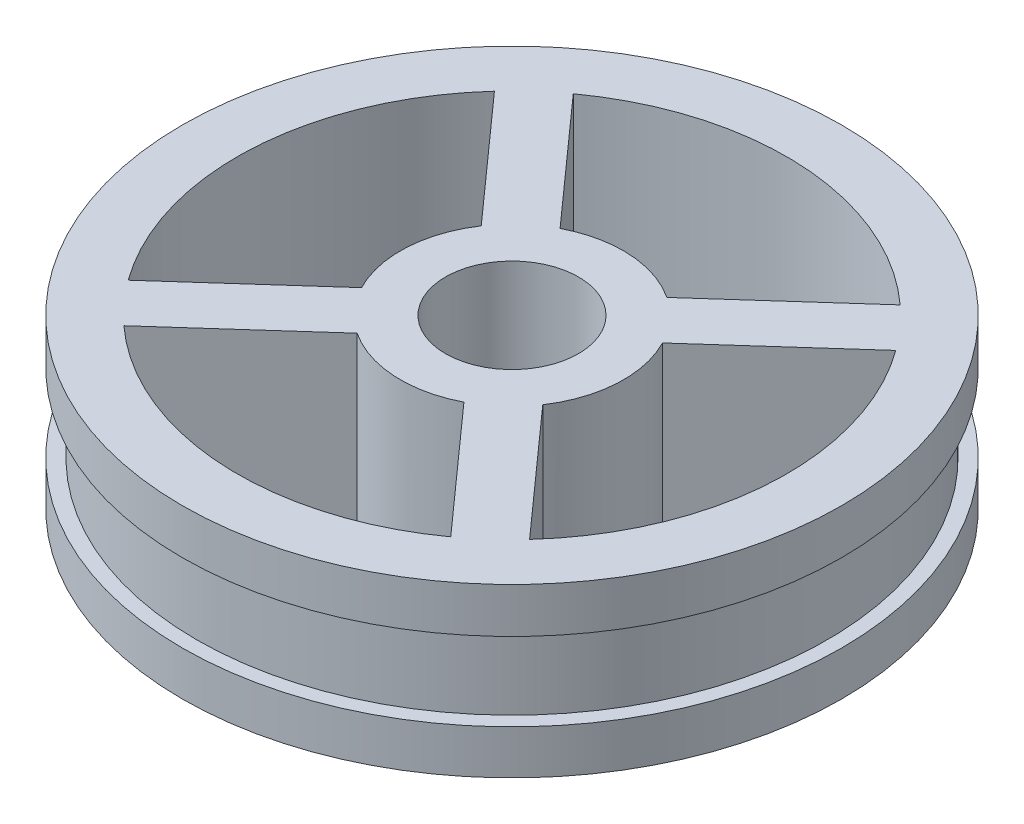
from build123d import *

# Parameters (mm, degrees)
SKETCH1_R                = 30
SKETCH1_R_2              = 25
BOSS_EXTRUDE1_DEPTH      = 15.24
BOSS_EXTRUDE2_DEPTH      = 15.24
SKETCH3_R                = 10.16
BOSS_EXTRUDE3_DEPTH      = 10
BOSS_EXTRUDE3_DEPTH_BACK = 15.24
SKETCH14_R               = 38.1
SKETCH14_R_2             = 28.702
CUT_EXTRUDE1_DEPTH       = 0.89229946
CUT_EXTRUDE1_DEPTH_BACK  = 6.22629946
CUT_EXTRUDE2_DEPTH       = 6.35
SKETCH19_R               = 2.032
CUT_EXTRUDE3_DEPTH       = 18.89
SKETCH20_R               = 6.052064437
CUT_EXTRUDE4_DEPTH       = 15.24


with BuildPart() as part:
    # Sketch1 → Boss-Extrude1 (new body)
    with BuildSketch(Plane(origin=(0, 0, 0), x_dir=(1, 0, 0), z_dir=(0, 1, 0))):
        Circle(SKETCH1_R)
        Circle(SKETCH1_R_2, mode=Mode.SUBTRACT)
    extrude(amount=BOSS_EXTRUDE1_DEPTH)

    # Sketch2 → Boss-Extrude2 (add)
    with BuildSketch(Plane(origin=(0, 15.24, 0), x_dir=(1, 0, 0), z_dir=(0, 1, 0))):
        Polygon((3.584352377, -0.200805771), (0.201044225, 3.588608735), (-3.584352377, 0.200805771), (-0.201044225, -3.588608735), align=None)
        with BuildLine():
            ThreePointArc((20.22640903, 14.693276617), (18.628907162, 16.672246937), (16.838608452, 18.478670552))
            Line((16.838608452, 18.478670552), (0.201044225, 3.588608735))
            Line((0.201044225, 3.588608735), (3.584352377, -0.200805771))
            Line((3.584352377, -0.200805771), (20.22640903, 14.693276617))
        make_face()
        with BuildLine():
            Line((-3.584352377, 0.200805771), (0.201044225, 3.588608735))
            Line((0.201044225, 3.588608735), (-14.669262011, 20.243832445))
            ThreePointArc((-14.669262011, 20.243832445), (-16.650126818, 18.648680301), (-18.458673848, 16.860526676))
            Line((-18.458673848, 16.860526676), (-3.584352377, 0.200805771))
        make_face()
        with BuildLine():
            Line((-0.201044225, -3.588608735), (-3.584352377, 0.200805771))
            Line((-3.584352377, 0.200805771), (-20.22640903, -14.693276617))
            ThreePointArc((-20.22640903, -14.693276617), (-18.628907162, -16.672246937), (-16.838608452, -18.478670552))
            Line((-16.838608452, -18.478670552), (-0.201044225, -3.588608735))
        make_face()
        with BuildLine():
            Line((18.458673848, -16.860526676), (3.584352377, -0.200805771))
            Line((3.584352377, -0.200805771), (-0.201044225, -3.588608735))
            Line((-0.201044225, -3.588608735), (14.669262011, -20.243832445))
            ThreePointArc((14.669262011, -20.243832445), (16.650126818, -18.648680301), (18.458673848, -16.860526676))
        make_face()
    extrude(amount=-BOSS_EXTRUDE2_DEPTH)

    # Sketch3 → Boss-Extrude3 (add, two sides)
    with BuildSketch(Plane(origin=(0, 0, 0), x_dir=(-1, 0, 0), z_dir=(0, -1, 0))) as boss_extrude3_sk:
        Circle(SKETCH3_R)
    extrude(amount=BOSS_EXTRUDE3_DEPTH)
    extrude(boss_extrude3_sk.sketch, amount=-BOSS_EXTRUDE3_DEPTH_BACK)

    # Sketch14 → Cut-Extrude1 (cut, two sides)
    with BuildSketch(Plane(origin=(0, 10.2489, 0), x_dir=(1, 0, 0), z_dir=(0, 1, 0))) as cut_extrude1_sk:
        Circle(SKETCH14_R)
        Circle(SKETCH14_R_2, mode=Mode.SUBTRACT)
    extrude(amount=CUT_EXTRUDE1_DEPTH, mode=Mode.SUBTRACT)
    extrude(cut_extrude1_sk.sketch, amount=-CUT_EXTRUDE1_DEPTH_BACK, mode=Mode.SUBTRACT)

    # Sketch18 → Cut-Extrude2 (cut)
    with BuildSketch(Plane.XZ.offset(10)):
        Polygon((7.18570145, 0), (3.592850725, 6.223), (-3.592850725, 6.223), (-7.18570145, 0), (-3.592850725, -6.223), (3.592850725, -6.223), align=None)
    extrude(amount=-CUT_EXTRUDE2_DEPTH, mode=Mode.SUBTRACT)

    # Sketch19 → Cut-Extrude3 (cut)
    with BuildSketch(Plane.XZ.offset(3.65)):
        Circle(SKETCH19_R)
    extrude(amount=-CUT_EXTRUDE3_DEPTH, mode=Mode.SUBTRACT)

    # Sketch20 → Cut-Extrude4 (cut)
    with BuildSketch(Plane(origin=(0, 15.24, 0), x_dir=(1, 0, 0), z_dir=(0, 1, 0))):
        Circle(SKETCH20_R)
    extrude(amount=-CUT_EXTRUDE4_DEPTH, mode=Mode.SUBTRACT)


solid = part.part
